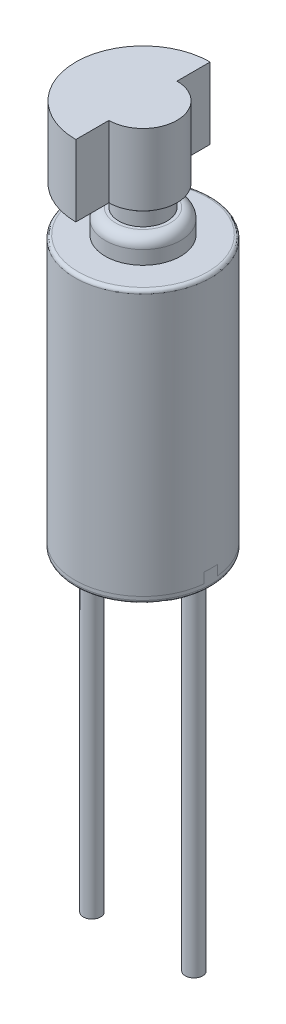
from build123d import *

# Parameters (mm, degrees)
SKETCH1_R              = 2
BOSS_EXTRUDE1_DEPTH    = 8
SKETCH2_R              = 1.105
BOSS_EXTRUDE2_DEPTH    = 0.7
SKETCH3_R              = 0.71
BOSS_EXTRUDE3_DEPTH    = 0.6
SKETCH4_R              = 0.335
BOSS_EXTRUDE4_DEPTH    = 2.11
SPLIT1_SURFACE_1_BACK  = 13.735
SPLIT1_SURFACE_1_DEPTH = 27.47
SPLIT1_SURFACE_2_BACK  = 13.735
SPLIT1_SURFACE_2_DEPTH = 27.47
FILLET1_R              = 0.1
FILLET2_R              = 0.1
FILLET3_R              = 0.3
CHAMFER1_SIZE          = 0.2
FILLET4_R              = 0.1
SKETCH6_R              = 0.255
BOSS_EXTRUDE5_DEPTH    = 10
BOSS_EXTRUDE5_2_DEPTH  = 10
SKETCH7_R              = 1.975
BOSS_EXTRUDE6_DEPTH    = 2.1
CUT_EXTRUDE1_DEPTH     = 2.1


with BuildPart() as part:
    # Sketch1 → Boss-Extrude1 (new body)
    with BuildSketch(Plane(origin=(0, 0, 0), x_dir=(1, 0, 0), z_dir=(0, 1, 0))):
        with Locations(Location((0, 0, 0), (0, 0, 270))):
            Circle(SKETCH1_R)
    extrude(amount=BOSS_EXTRUDE1_DEPTH)

    # Sketch2 → Boss-Extrude2 (add)
    with BuildSketch(Plane(origin=(0, 8, 0), x_dir=(1, 0, 0), z_dir=(0, 1, 0))):
        with Locations(Location((0, 0, 0), (0, 0, 270))):
            Circle(SKETCH2_R)
    extrude(amount=BOSS_EXTRUDE2_DEPTH)


with BuildPart() as body_2:
    # Sketch3 → Boss-Extrude3 (new body)
    with BuildSketch(Plane(origin=(0, 8.7, 0), x_dir=(1, 0, 0), z_dir=(0, 1, 0))):
        with Locations(Location((0, 0, 0), (0, 0, 270))):
            Circle(SKETCH3_R)
    extrude(amount=BOSS_EXTRUDE3_DEPTH)

    # Chamfer1
    chamfer1_edges = [body_2.edges().sort_by_distance(p)[0] for p in [
        (0, 9.3, -0.71),
    ]]
    chamfer(chamfer1_edges, length=CHAMFER1_SIZE)


with BuildPart() as body_3:
    # Sketch4 → Boss-Extrude4 (new body)
    with BuildSketch(Plane(origin=(0, 9.3, 0), x_dir=(1, 0, 0), z_dir=(0, 1, 0))):
        with Locations(Location((0, 0, 0), (0, 0, 270))):
            Circle(SKETCH4_R)
    extrude(amount=BOSS_EXTRUDE4_DEPTH)

    # Fillet4
    fillet4_edges = [body_3.edges().sort_by_distance(p)[0] for p in [
        (0, 11.41, -0.335),
    ]]
    fillet(fillet4_edges, radius=FILLET4_R)

    # Sketch7 → Boss-Extrude6 (add)
    with BuildSketch(Plane(origin=(0, 11.41, 0), x_dir=(1, 0, 0), z_dir=(0, 1, 0))):
        with Locations(Location((0, 0, 0), (0, 0, 270))):
            Circle(SKETCH7_R)
    extrude(amount=-BOSS_EXTRUDE6_DEPTH)

    # Sketch8 → Cut-Extrude1 (cut)
    with BuildSketch(Plane(origin=(0, 11.41, 0), x_dir=(1, 0, 0), z_dir=(0, 1, 0))):
        with BuildLine():
            ThreePointArc((1.975, 0), (1.396535893, 1.396535893), (0, 1.975))
            Line((0, 1.975), (0, 1))
            ThreePointArc((0, 1), (0.707106781, 0.707106781), (1, 0))
            ThreePointArc((1, 0), (0.707106781, -0.707106781), (0, -1))
            Line((0, -1), (0, -1.975))
            ThreePointArc((0, -1.975), (1.396535893, -1.396535893), (1.975, 0))
        make_face()
    extrude(amount=-CUT_EXTRUDE1_DEPTH, mode=Mode.SUBTRACT)


with BuildPart() as body_4:
    # Split1: the piece behind the surface
    add(part.part)
    # Split1 surface: a surface, the sketch's curves swept straight by 27.47 mm
    with BuildLine(Plane(origin=(0, 0, 0), x_dir=(0, 0, -1), z_dir=(1, 0, 0)).offset(-SPLIT1_SURFACE_1_BACK), mode=Mode.PRIVATE) as split1_surface_1_path:
        Line((-2, 0.2), (-0.2, 0.2))
        Line((-0.2, 0.2), (-0.2, 0.5))
        Line((-0.2, 0.5), (0.2, 0.5))
        Line((0.2, 0.5), (0.2, 0.2))
        Line((0.2, 0.2), (2, 0.2))
    split1_surface_1 = Shell.extrude(split1_surface_1_path.wire(), (1 * SPLIT1_SURFACE_1_DEPTH, 0 * SPLIT1_SURFACE_1_DEPTH, 0 * SPLIT1_SURFACE_1_DEPTH))
    split(bisect_by=split1_surface_1, keep=Keep.BOTTOM)

    # Fillet1
    fillet1_edges = [body_4.edges().sort_by_distance(p)[0] for p in [
        (0, 0, -2),
    ]]
    fillet(fillet1_edges, radius=FILLET1_R)


with BuildPart() as part_1:
    add(part.part)

    # Split1: split by a surface, the side it looks to stays
    # Split1 surface: a surface, the sketch's curves swept straight by 27.47 mm
    with BuildLine(Plane(origin=(0, 0, 0), x_dir=(0, 0, -1), z_dir=(1, 0, 0)).offset(-SPLIT1_SURFACE_2_BACK), mode=Mode.PRIVATE) as split1_surface_2_path:
        Line((-2, 0.2), (-0.2, 0.2))
        Line((-0.2, 0.2), (-0.2, 0.5))
        Line((-0.2, 0.5), (0.2, 0.5))
        Line((0.2, 0.5), (0.2, 0.2))
        Line((0.2, 0.2), (2, 0.2))
    split1_surface_2 = Shell.extrude(split1_surface_2_path.wire(), (1 * SPLIT1_SURFACE_2_DEPTH, 0 * SPLIT1_SURFACE_2_DEPTH, 0 * SPLIT1_SURFACE_2_DEPTH))
    split(bisect_by=split1_surface_2, keep=Keep.TOP)

    # Fillet2
    fillet2_edges = [part_1.edges().sort_by_distance(p)[0] for p in [
        (0, 8, -2),
    ]]
    fillet(fillet2_edges, radius=FILLET2_R)

    # Fillet3
    fillet3_edges = [part_1.edges().sort_by_distance(p)[0] for p in [
        (0, 8.7, -1.105),
    ]]
    fillet(fillet3_edges, radius=FILLET3_R)


with BuildPart() as body_5:
    # Sketch6 → Boss-Extrude5 (new body)
    with BuildSketch(Plane.XZ):
        with Locations(Location((-1.5, 0, 0), (0, 0, 270))):
            Circle(SKETCH6_R)
    extrude(amount=BOSS_EXTRUDE5_DEPTH)


with BuildPart() as body_6:
    # Sketch6 → Boss-Extrude5 2 (new body)
    with BuildSketch(Plane.XZ):
        with Locations(Location((1.5, 0, 0), (0, 0, 90))):
            Circle(SKETCH6_R)
    extrude(amount=BOSS_EXTRUDE5_2_DEPTH)


solid = Compound([body_2.part, body_3.part, body_4.part, part_1.part, body_5.part, body_6.part])
